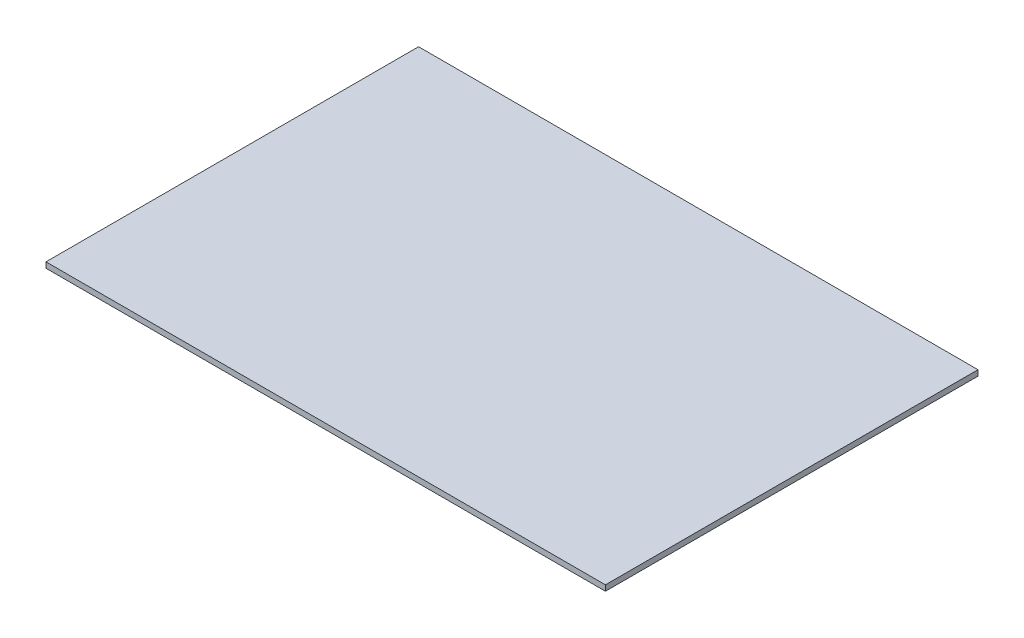
from build123d import *

# Parameters (mm, degrees)
ESQUISSE1_W      = 1000
ESQUISSE1_H      = 666
EXTRUSION1_DEPTH = 10


with BuildPart() as part:
    # Esquisse1 → Extrusion1 (new body)
    with BuildSketch(Plane(origin=(0, 0, 0), x_dir=(1, 0, 0), z_dir=(0, 1, 0))):
        with Locations((500, 333)):
            Rectangle(ESQUISSE1_W, ESQUISSE1_H)
    extrude(amount=EXTRUSION1_DEPTH)


solid = part.part
